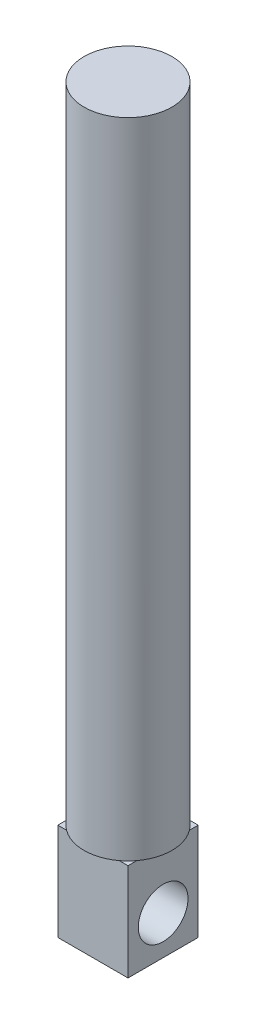
from build123d import *

# Parameters (mm, degrees)
SKETCH1_W           = 6
SKETCH1_H           = 6
BOSS_EXTRUDE1_DEPTH = 8.31
SKETCH2_R           = 2.125
CUT_EXTRUDE1_DEPTH  = 10
SKETCH3_R           = 3.75
BOSS_EXTRUDE2_DEPTH = 55


with BuildPart() as part:
    # Sketch1 → Boss-Extrude1 (new body)
    with BuildSketch(Plane(origin=(0, 0, 0), x_dir=(1, 0, 0), z_dir=(0, 1, 0))):
        with Locations((3, 3)):
            Rectangle(SKETCH1_W, SKETCH1_H)
    extrude(amount=BOSS_EXTRUDE1_DEPTH)

    # Sketch2 → Cut-Extrude1 (cut)
    with BuildSketch(Plane(origin=(6, 0, 0), x_dir=(0, 0, -1), z_dir=(1, 0, 0))):
        with Locations((3, 3.31)):
            Circle(SKETCH2_R)
    extrude(amount=-CUT_EXTRUDE1_DEPTH, mode=Mode.SUBTRACT)

    # Sketch3 → Boss-Extrude2 (add)
    with BuildSketch(Plane(origin=(0, 8.31, 0), x_dir=(1, 0, 0), z_dir=(0, 1, 0))):
        with Locations((3, 3)):
            Circle(SKETCH3_R)
    extrude(amount=BOSS_EXTRUDE2_DEPTH)


solid = part.part
